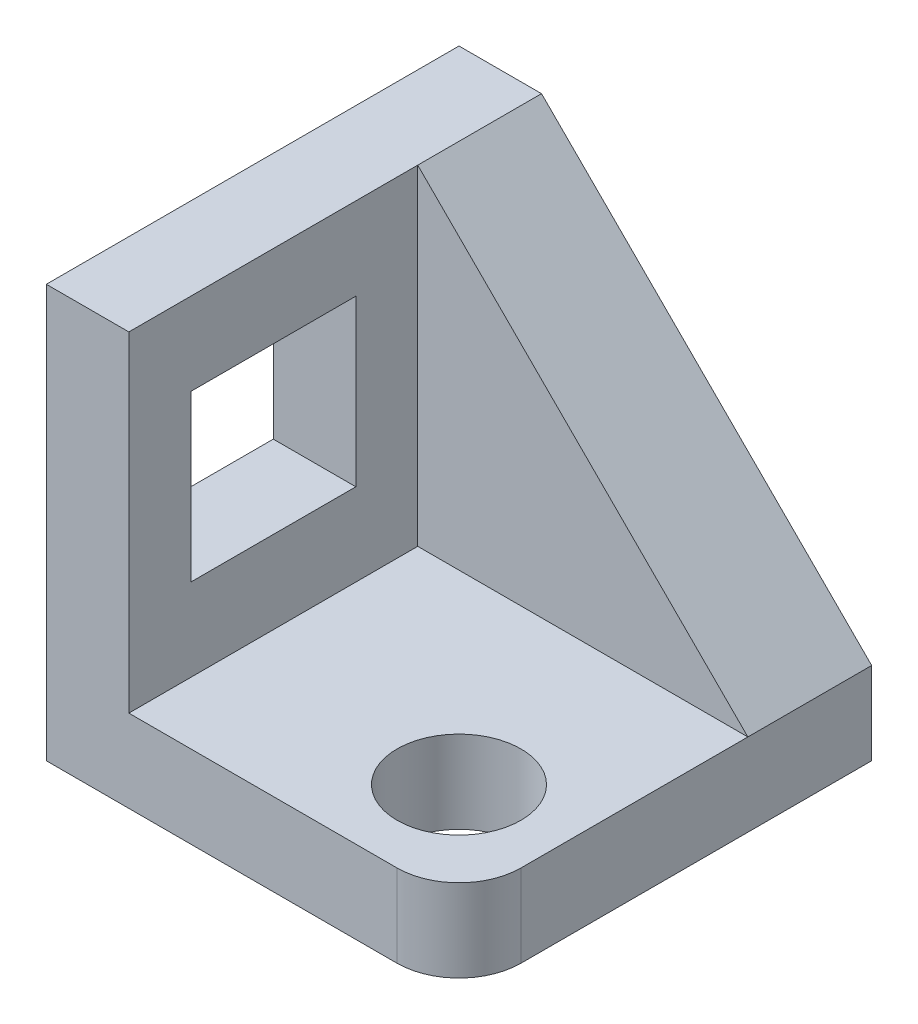
from build123d import *

# Parameters (mm, degrees)
CROQUIS1_W              = 100
CROQUIS1_H              = 100
SALIENTE_EXTRUIR1_DEPTH = 20
CROQUIS2_W              = 20
CROQUIS2_H              = 100
SALIENTE_EXTRUIR2_DEPTH = 80
CROQUIS3_W              = 80
CROQUIS3_H              = 30
SALIENTE_EXTRUIR3_DEPTH = 80
CORTAR_EXTRUIR1_DEPTH   = 80
CROQUIS5_R              = 15
CORTAR_EXTRUIR2_DEPTH   = 80
REDONDEO1_R             = 15
CROQUIS6_W              = 40
CROQUIS6_H              = 40
CORTAR_EXTRUIR3_DEPTH   = 80


with BuildPart() as part:
    # Croquis1 → Saliente-Extruir1 (new body)
    with BuildSketch(Plane(origin=(0, 0, 0), x_dir=(1, 0, 0), z_dir=(0, 1, 0))):
        Rectangle(CROQUIS1_W, CROQUIS1_H)
    extrude(amount=SALIENTE_EXTRUIR1_DEPTH)

    # Croquis2 → Saliente-Extruir2 (add)
    with BuildSketch(Plane(origin=(0, 20, 0), x_dir=(1, 0, 0), z_dir=(0, 1, 0))):
        with Locations((-40, 0)):
            Rectangle(CROQUIS2_W, CROQUIS2_H)
    extrude(amount=SALIENTE_EXTRUIR2_DEPTH)

    # Croquis3 → Saliente-Extruir3 (add)
    with BuildSketch(Plane(origin=(0, 20, 0), x_dir=(1, 0, 0), z_dir=(0, 1, 0))):
        with Locations((10, 35)):
            Rectangle(CROQUIS3_W, CROQUIS3_H)
    extrude(amount=SALIENTE_EXTRUIR3_DEPTH)

    # Croquis4 → Cortar-Extruir1 (cut)
    with BuildSketch(Plane.XY.offset(-20)):
        Polygon((50, 20), (-30, 100), (50, 100), align=None)
    extrude(amount=-CORTAR_EXTRUIR1_DEPTH, mode=Mode.SUBTRACT)

    # Croquis5 → Cortar-Extruir2 (cut)
    with BuildSketch(Plane(origin=(0, 20, 0), x_dir=(1, 0, 0), z_dir=(0, 1, 0))):
        with Locations((25, -25)):
            Circle(CROQUIS5_R)
    extrude(amount=-CORTAR_EXTRUIR2_DEPTH, mode=Mode.SUBTRACT)

    # Redondeo1
    redondeo1_edges = [part.edges().sort_by_distance(p)[0] for p in [
        (50, 10, 50),
    ]]
    fillet(redondeo1_edges, radius=REDONDEO1_R)

    # Croquis6 → Cortar-Extruir3 (cut)
    with BuildSketch(Plane(origin=(-30, 0, 0), x_dir=(0, 0, -1), z_dir=(1, 0, 0))):
        with Locations((-15, 60)):
            Rectangle(CROQUIS6_W, CROQUIS6_H)
    extrude(amount=-CORTAR_EXTRUIR3_DEPTH, mode=Mode.SUBTRACT)


solid = part.part
